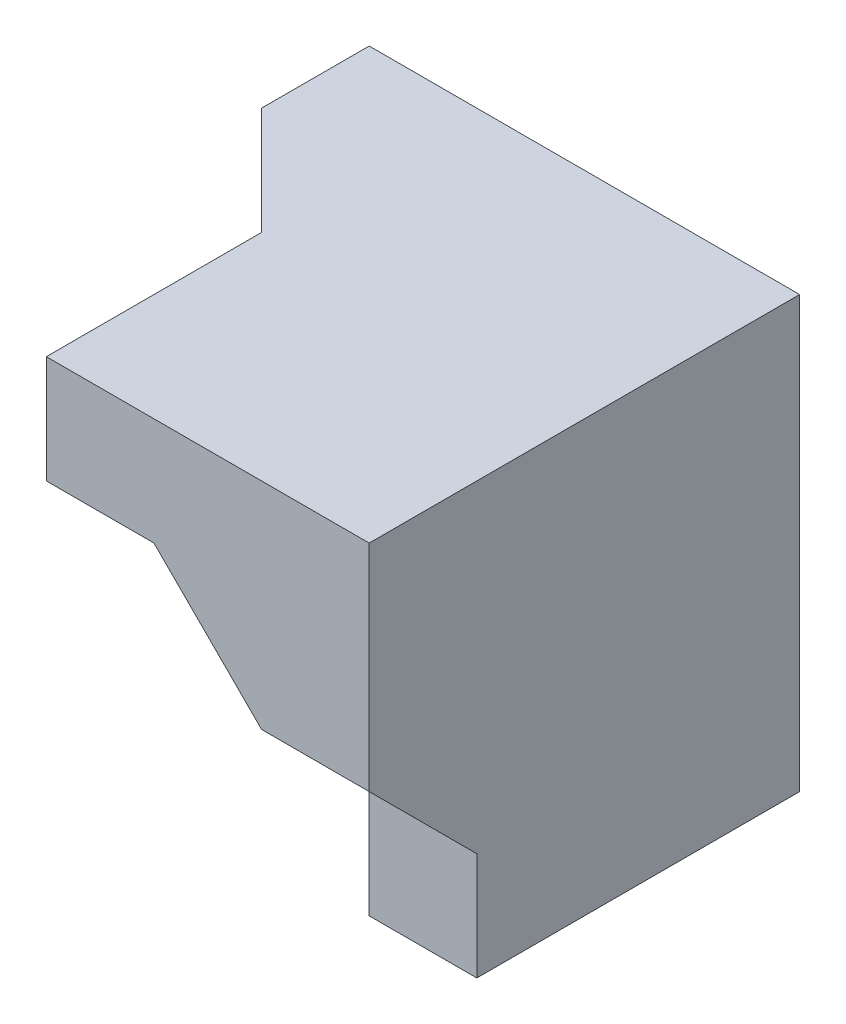
from build123d import *

# Parameters (mm, degrees)
SKETCH1_W            = 40
SKETCH1_H            = 40
BOSS_EXTRUDE1_DEPTH  = 20
BOSS_EXTRUDE3_DEPTH  = 10
SKETCH3_W            = 10
SKETCH3_H            = 30
BOSS_EXTRUDE5_DEPTH  = 10
BOSS_EXTRUDE6_DEPTH  = 10
SKETCH5_W            = 10
SKETCH5_H            = 40
CUT_EXTRUDE3_DEPTH   = 25
CUT_EXTRUDE4_DEPTH   = 25
CUT_EXTRUDE5_DEPTH   = 10
SKETCH9_W            = 20
SKETCH9_H            = 20
BOSS_EXTRUDE7_DEPTH  = 10
CUT_EXTRUDE6_DEPTH   = 10
BOSS_EXTRUDE8_DEPTH  = 10
SKETCH12_W           = 20
SKETCH12_H           = 10
BOSS_EXTRUDE9_DEPTH  = 20
BOSS_EXTRUDE10_DEPTH = 20
BOSS_EXTRUDE11_DEPTH = 20
BOSS_EXTRUDE12_DEPTH = 17


with BuildPart() as part:
    # Sketch1 → Boss-Extrude1 (new body)
    with BuildSketch(Plane.XY):
        with Locations((20, 20)):
            Rectangle(SKETCH1_W, SKETCH1_H)
    extrude(amount=BOSS_EXTRUDE1_DEPTH)

    # Sketch3 → Boss-Extrude5 (add)
    with BuildSketch(Plane(origin=(40, 0, 0), x_dir=(0, 0, -1), z_dir=(1, 0, 0))):
        with Locations((-25, 25)):
            Rectangle(SKETCH3_W, SKETCH3_H)
    extrude(amount=-BOSS_EXTRUDE5_DEPTH)



with BuildPart() as body_2:
    # Sketch2 → Boss-Extrude3 (new body)
    with BuildSketch(Plane(origin=(40, 0, 0), x_dir=(0, 0, -1), z_dir=(1, 0, 0))):
        Polygon((-30, 10), (-20, 0), (-30, 0), align=None)
    extrude(amount=-BOSS_EXTRUDE3_DEPTH)


with BuildPart() as part_1:
    add(part.part)

    add(body_2.part)  # Boss-Extrude6 merges body 2
    # Sketch4 → Boss-Extrude6 (add)
    with BuildSketch(Plane(origin=(40, 0, 0), x_dir=(0, 0, -1), z_dir=(1, 0, 0))):
        Polygon((-20, 0), (-20, 10), (-30, 10), align=None)
    extrude(amount=-BOSS_EXTRUDE6_DEPTH)

    # Sketch5 → Cut-Extrude3 (cut)
    with BuildSketch(Plane.XY.offset(20)):
        with Locations((5, 20)):
            Rectangle(SKETCH5_W, SKETCH5_H)
    extrude(amount=-CUT_EXTRUDE3_DEPTH, mode=Mode.SUBTRACT)

    # Sketch7 → Cut-Extrude4 (cut)
    with BuildSketch(Plane.XY.offset(20)):
        Polygon((10, 10), (20, 0), (10, 0), align=None)
    extrude(amount=-CUT_EXTRUDE4_DEPTH, mode=Mode.SUBTRACT)

    # Sketch8 → Cut-Extrude5 (cut)
    with BuildSketch(Plane.XY.offset(20)):
        Polygon((30, 0), (10, 20), (10, 10), (20, 0), align=None)
    extrude(amount=-CUT_EXTRUDE5_DEPTH, mode=Mode.SUBTRACT)

    # Sketch9 → Boss-Extrude7 (add)
    with BuildSketch(Plane.ZY.offset(-10)):
        with Locations((10, 30)):
            Rectangle(SKETCH9_W, SKETCH9_H)
    extrude(amount=BOSS_EXTRUDE7_DEPTH)

    # Sketch10 → Cut-Extrude6 (cut)
    with BuildSketch(Plane(origin=(0, 40, 0), x_dir=(1, 0, 0), z_dir=(0, 1, 0))):
        Polygon((10, -20), (0, -10), (0, -20), align=None)
    extrude(amount=-CUT_EXTRUDE6_DEPTH, mode=Mode.SUBTRACT)

    # Sketch11 → Boss-Extrude8 (add)
    with BuildSketch(Plane.ZY.offset(-30)):
        Polygon((30, 10), (40, 20), (40, 40), (30, 40), align=None)
    extrude(amount=-BOSS_EXTRUDE8_DEPTH)

    # Sketch12 → Boss-Extrude9 (add)
    with BuildSketch(Plane.ZY.offset(-30)):
        with Locations((30, 35)):
            Rectangle(SKETCH12_W, SKETCH12_H)
    extrude(amount=BOSS_EXTRUDE9_DEPTH)

    # Sketch13 → Boss-Extrude10 (add)
    with BuildSketch(Plane.XY.offset(40)):
        Polygon((30, 20), (20, 30), (30, 30), align=None)
    extrude(amount=-BOSS_EXTRUDE10_DEPTH)

    # Sketch16 → Boss-Extrude11 (add)
    with BuildSketch(Plane.ZY.offset(-10)):
        Polygon((20, 20), (30, 30), (20, 30), align=None)
    extrude(amount=-BOSS_EXTRUDE11_DEPTH)

    # Sketch17 → Boss-Extrude12 (add)
    with BuildSketch(Plane(origin=(3.333333333, 3.333333333, -3.333333333), x_dir=(-0.816496581, 0.40824829, -0.40824829), z_dir=(0.577350269, 0.577350269, -0.577350269))):
        Polygon((-32.659863237, 42.426406871), (-20.412414523, 49.497474683), (-8.164965809, 42.426406871), (-8.164965809, 28.284271247), (-32.659863237, 14.142135624), align=None)
    extrude(amount=BOSS_EXTRUDE12_DEPTH)


solid = part_1.part
